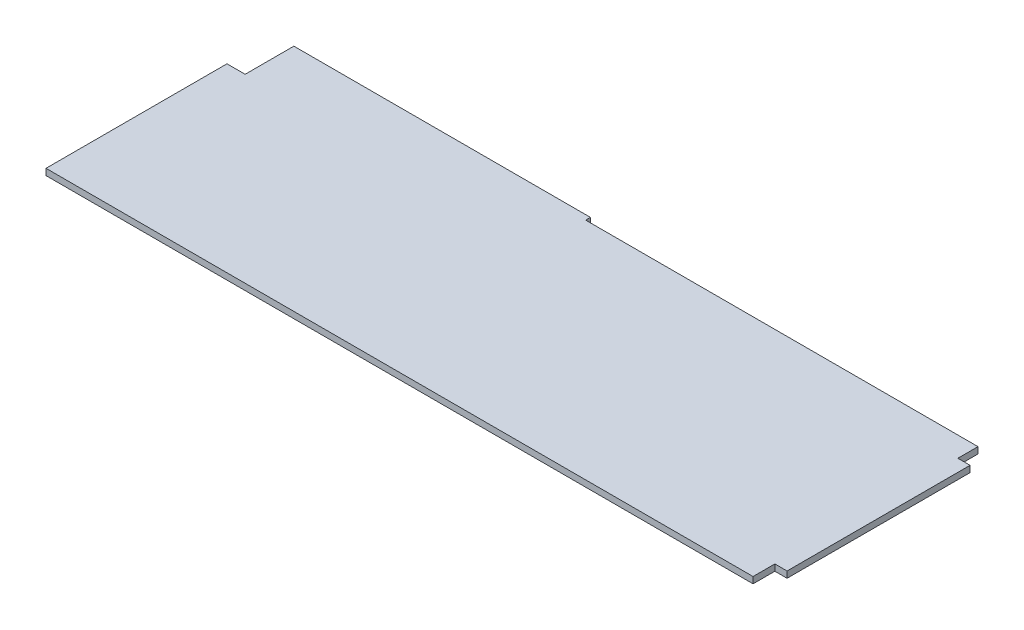
from build123d import *

# Parameters (mm, degrees)
BOSS_EXTRUDE1_DEPTH = 2.67


with BuildPart() as part:
    # Sketch1 → Boss-Extrude1 (new body)
    with BuildSketch(Plane(origin=(0, 0, 0), x_dir=(1, 0, 0), z_dir=(0, 1, 0))):
        Polygon((0, 0), (0, 75.95), (7.62, 75.95), (7.62, 96.4), (132.07, 96.4), (132.07, 94.4), (296.72, 94.4), (296.72, 85.95), (301.84, 85.95), (301.84, 9.15), (296.72, 9.15), (296.72, 0), align=None)
    extrude(amount=BOSS_EXTRUDE1_DEPTH)


solid = part.part
